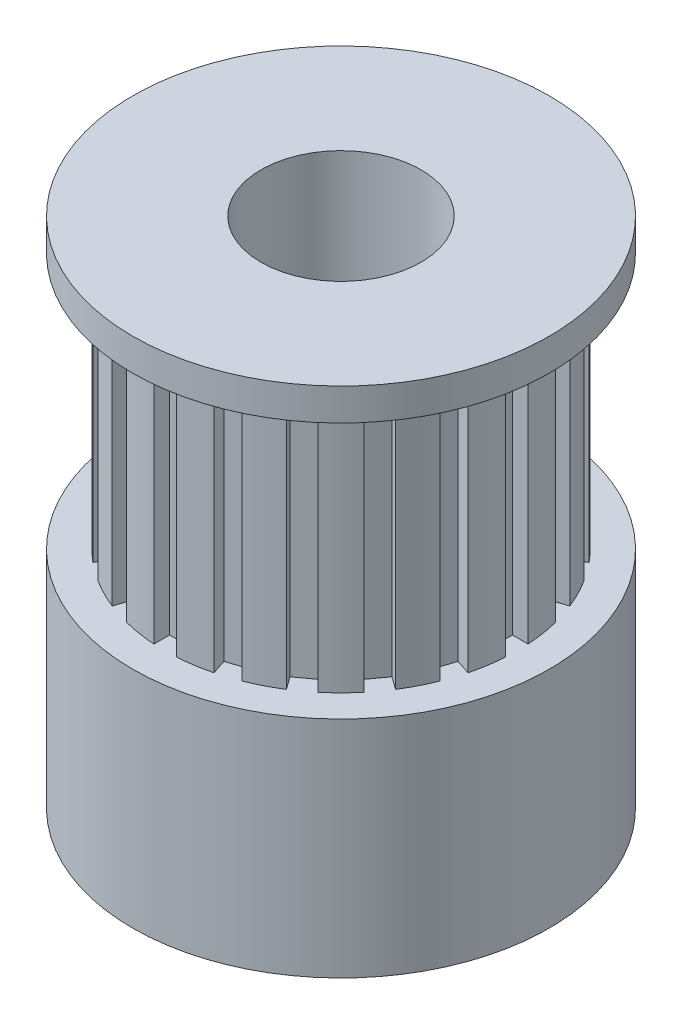
from build123d import *

# Parameters (mm, degrees)
SKETCH1_R           = 6.5
SKETCH1_R_2         = 2.5
BOSS_EXTRUDE1_DEPTH = 16
SKETCH2_W           = 1
SKETCH2_H           = 8
SKETCH3_R           = 1.5
CUT_EXTRUDE1_DEPTH  = 7.5
CIRPATTERN1_COUNT   = 2
CIRPATTERN1_ANGLE   = 90
SKETCH6_W           = 0.7
SKETCH6_H           = 8
CUT_EXTRUDE2_DEPTH  = 0.5
CIRPATTERN2_COUNT   = 20


with BuildPart() as part:
    # Sketch1 → Boss-Extrude1 (new body)
    with BuildSketch(Plane(origin=(0, 0, 0), x_dir=(1, 0, 0), z_dir=(0, 1, 0))):
        Circle(SKETCH1_R)
        Circle(SKETCH1_R_2, mode=Mode.SUBTRACT)
    extrude(amount=BOSS_EXTRUDE1_DEPTH)

    # Sketch2 → Cut-Revolve1 (revolve, cut)
    with BuildSketch(Plane.XY):
        with Locations((6, 11)):
            Rectangle(SKETCH2_W, SKETCH2_H)
    revolve(axis=Axis((0, 18.194841433, 0), (0, -1, 0)), mode=Mode.SUBTRACT)

    # Sketch3 → Cut-Extrude1 (cut, through all)
    with BuildSketch(Plane.XY):
        with Locations((0, 3.5)):
            Circle(SKETCH3_R)
    cut_extrude1 = extrude(amount=-CUT_EXTRUDE1_DEPTH, mode=Mode.SUBTRACT)

    # CirPattern1: Cut-Extrude1 ×2 about axis
    cirpattern1_axis = Axis((0, 16, 0), (0, 1, 0))
    for i in range(1, CIRPATTERN1_COUNT):
        add(cut_extrude1.rotate(cirpattern1_axis, i * CIRPATTERN1_ANGLE / (CIRPATTERN1_COUNT - 1)), mode=Mode.SUBTRACT)

    # Sketch6 → Cut-Extrude2 (cut)
    with BuildSketch(Plane.XY.offset(5.5)):
        with Locations((0, 11)):
            Rectangle(SKETCH6_W, SKETCH6_H)
    cut_extrude2 = extrude(amount=-CUT_EXTRUDE2_DEPTH, mode=Mode.SUBTRACT)

    # CirPattern2: Cut-Extrude2 ×20 about axis
    cirpattern2_axis = Axis((0, 0, 0), (0, 1, 0))
    for i in range(1, CIRPATTERN2_COUNT):
        add(cut_extrude2.rotate(cirpattern2_axis, i * 360 / CIRPATTERN2_COUNT), mode=Mode.SUBTRACT)


solid = part.part
